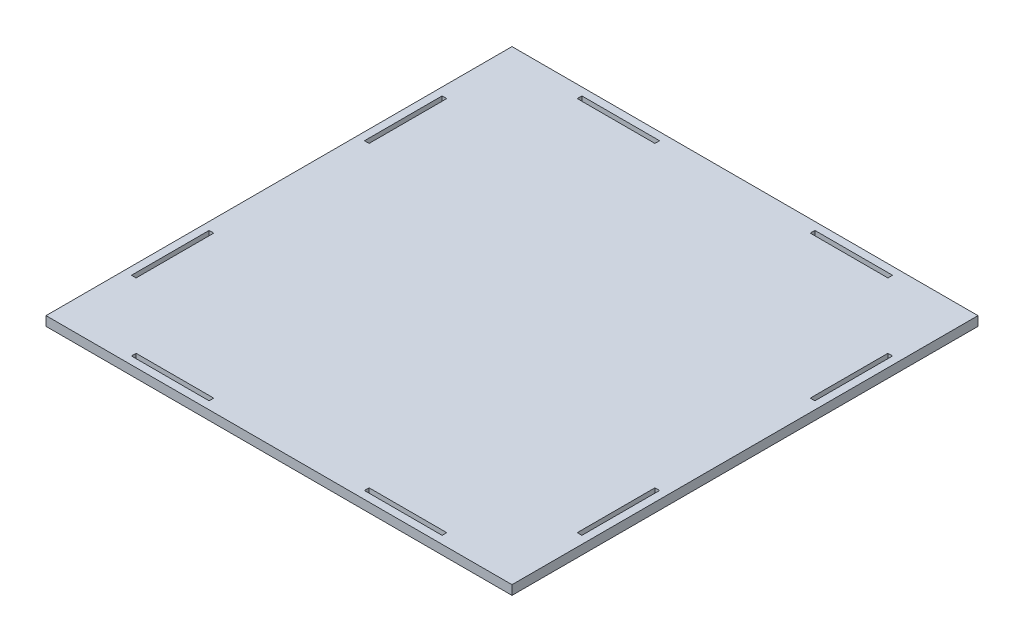
from build123d import *

# Parameters (mm, degrees)
SKETCH1_W           = 300
SKETCH1_H           = 300
SKETCH1_W_2         = 50
SKETCH1_H_2         = 3
SKETCH1_W_3         = 3
SKETCH1_H_3         = 50
BOSS_EXTRUDE1_DEPTH = 6


with BuildPart() as part:
    # Sketch1 → Boss-Extrude1 (new body)
    with BuildSketch(Plane(origin=(0, 0, 0), x_dir=(1, 0, 0), z_dir=(0, 1, 0))):
        Rectangle(SKETCH1_W, SKETCH1_H)
        with Locations((-75, 143.5)):
            Rectangle(SKETCH1_W_2, SKETCH1_H_2, mode=Mode.SUBTRACT)
        with Locations((75, 143.5)):
            Rectangle(SKETCH1_W_2, SKETCH1_H_2, mode=Mode.SUBTRACT)
        with Locations((143.5, -75)):
            Rectangle(SKETCH1_W_3, SKETCH1_H_3, mode=Mode.SUBTRACT)
        with Locations((143.5, 75)):
            Rectangle(SKETCH1_W_3, SKETCH1_H_3, mode=Mode.SUBTRACT)
        with Locations((75, -143.5)):
            Rectangle(SKETCH1_W_2, SKETCH1_H_2, mode=Mode.SUBTRACT)
        with Locations((-75, -143.5)):
            Rectangle(SKETCH1_W_2, SKETCH1_H_2, mode=Mode.SUBTRACT)
        with Locations((-143.5, 75)):
            Rectangle(SKETCH1_W_3, SKETCH1_H_3, mode=Mode.SUBTRACT)
        with Locations((-143.5, -75)):
            Rectangle(SKETCH1_W_3, SKETCH1_H_3, mode=Mode.SUBTRACT)
    extrude(amount=BOSS_EXTRUDE1_DEPTH)


solid = part.part
